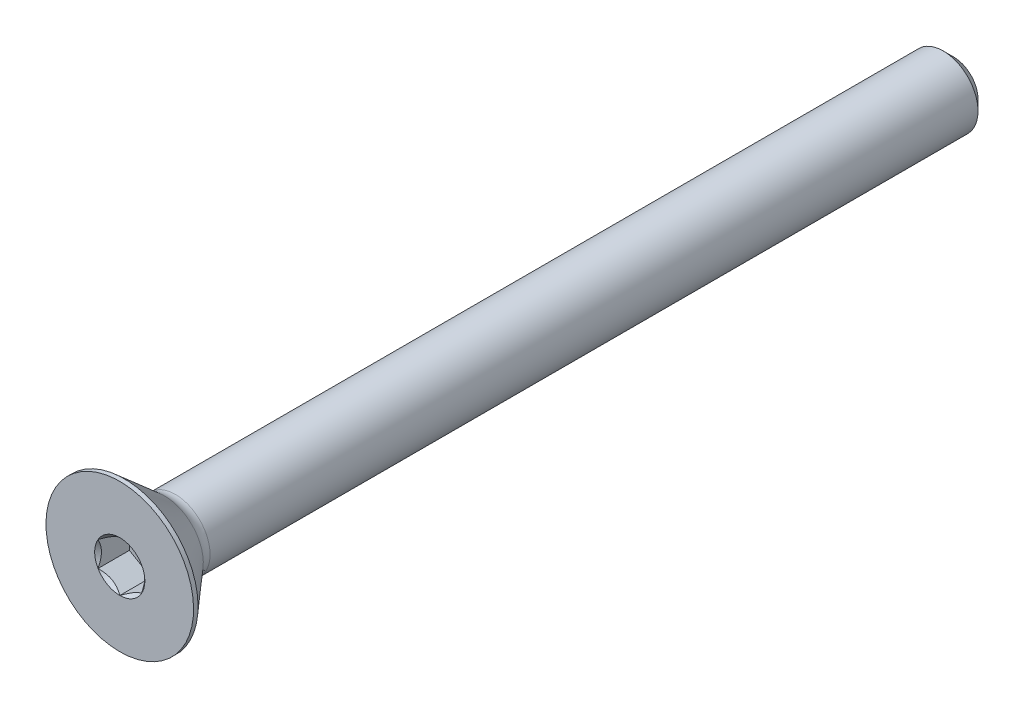
from build123d import *

# Parameters (mm, degrees)
SKETCH1_W           = 76.2
SKETCH1_H           = 3.175
CHAMFER1_SIZE       = 0.9525
CUT_EXTRUDE2_DEPTH  = 2.86258
BOSS_EXTRUDE2_START = -45.722795596
SKETCH9_R           = 3.175
BOSS_EXTRUDE2_DEPTH = 45.722795596


with BuildPart() as part:
    # Sketch1 → Revolve1 (revolve)
    with BuildSketch(Plane(origin=(0, 0, 0), x_dir=(0, 0, -1), z_dir=(1, 0, 0))):
        with Locations((38.1, 1.5875)):
            Rectangle(SKETCH1_W, SKETCH1_H)
    revolve(axis=Axis((0, 0, -76.2), (0, 0, 1)))

    # Chamfer1
    chamfer1_edges = [part.edges().sort_by_distance(p)[0] for p in [
        (0, -3.175, -76.2),
    ]]
    chamfer(chamfer1_edges, length=CHAMFER1_SIZE)

    # Sketch7 → Revolve2 (revolve)
    with BuildSketch(Plane(origin=(0, 0, 0), x_dir=(0, 0, -1), z_dir=(1, 0, 0)), mode=Mode.PRIVATE) as revolve2_sk:
        with BuildLine():
            Line((0, 6.7437), (0.40894, 6.7437))
            Line((0.40894, 6.7437), (4.0894, 3.544324933))
            ThreePointArc((4.0894, 3.544324933), (4.549909788, 3.270350399), (5.077204404, 3.175))
            Line((5.077204404, 3.175), (5.077204404, 0))
            Line((5.077204404, 0), (0, 0))
            Line((0, 0), (0, 6.7437))
        make_face()
    revolve(revolve2_sk.sketch.rotate(Axis((0, 0, 0), (0, 0, -1)), 180), axis=Axis((0, 0, 0), (0, 0, -1)))

    # Boss-Extrude1 cone 1 section (through the dimple's axis) → Boss-Extrude1 (revolve)
    with BuildSketch(Plane(origin=(0, 0, -5.077204404), x_dir=(0, -1, 0), z_dir=(1, 0, 0))):
        Polygon((0, 0), (3.175, 0), (0, 3.175), align=None)
    revolve(axis=Axis((0, 0, -5.077204404), (0, 0, -1)))

    # Sketch5 → Cut-Extrude2 (cut)
    with BuildSketch(Plane.XY):
        Polygon((1.984375, -1.14567944), (1.984375, 1.14567944), (0, 2.291358881), (-1.984375, 1.14567944), (-1.984375, -1.14567944), (0, -2.291358881), align=None)
    extrude(amount=-CUT_EXTRUDE2_DEPTH, mode=Mode.SUBTRACT)

    # Cut-Extrude3 cone 1 section (through the dimple's axis) → Cut-Extrude3 (revolve, cut)
    with BuildSketch(Plane(origin=(0, 0, 0), x_dir=(0, -1, 0), z_dir=(1, 0, 0))):
        Polygon((0, 0), (2.291358881, 0), (0, 2.291358881), align=None)
    revolve(axis=Axis((0, 0, 0), (0, 0, -1)), mode=Mode.SUBTRACT)

    # Sketch9 → Boss-Extrude2 (add)
    with BuildSketch(Plane.XY.offset(-5.077204404).offset(BOSS_EXTRUDE2_START)):
        with Locations(Location((0, 0, 0), (0, 0, 90))):
            Circle(SKETCH9_R)
    extrude(amount=BOSS_EXTRUDE2_DEPTH)


solid = part.part
